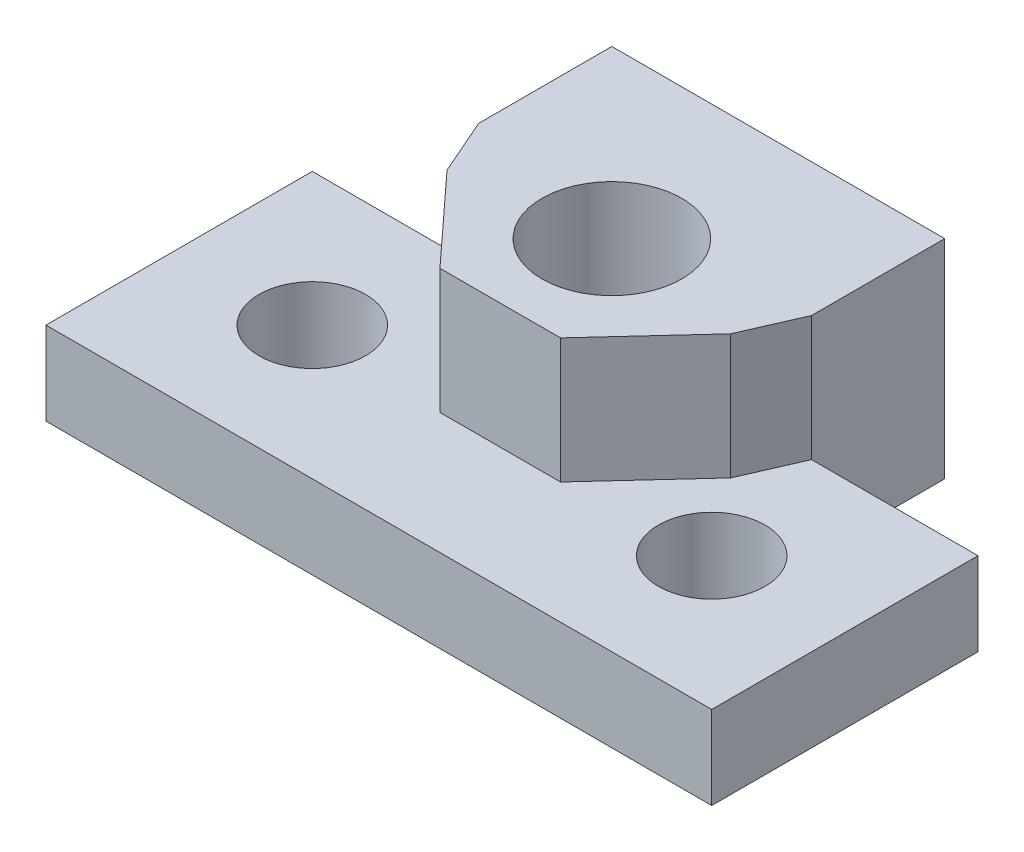
from build123d import *

# Parameters (mm, degrees)
SKETCH1_R           = 1.6
SKETCH1_R_2         = 2.5
BOSS_EXTRUDE1_DEPTH = 1.25
SKETCH2_R           = 2.1
BOSS_EXTRUDE2_DEPTH = 5


with BuildPart() as part:
    # Sketch1 → Boss-Extrude1 (new body, symmetric)
    with BuildSketch(Plane(origin=(0, 0, 0), x_dir=(1, 0, 0), z_dir=(0, 1, 0))):
        Polygon((-5, -1.666666667), (-10, -1.666666667), (-10, -9.666666667), (10, -9.666666667), (10, -1.666666667), (5, -1.666666667), (5, 2.333333333), (-5, 2.333333333), align=None)
        with Locations((-6, -5.666666667)):
            Circle(SKETCH1_R, mode=Mode.SUBTRACT)
        with Locations((6, -5.666666667)):
            Circle(SKETCH1_R, mode=Mode.SUBTRACT)
        with Locations((0, -2.666666667)):
            Circle(SKETCH1_R_2, mode=Mode.SUBTRACT)
    extrude(amount=BOSS_EXTRUDE1_DEPTH, both=True)

    # Sketch2 → Boss-Extrude2 (add)
    with BuildSketch(Plane(origin=(0, 0, 0), x_dir=(1, 0, 0), z_dir=(0, 1, 0))):
        Polygon((-5, 2.333333333), (-5, -1.666666667), (-4.260765506, -3.357761167), (-1.81082534, -6.020739609), (1.81082534, -6.020739609), (4.260765506, -3.357761167), (5, -1.666666667), (5, 2.333333333), align=None)
        with Locations((0, -2.666666667)):
            Circle(SKETCH2_R, mode=Mode.SUBTRACT)
    extrude(amount=BOSS_EXTRUDE2_DEPTH)


solid = part.part
